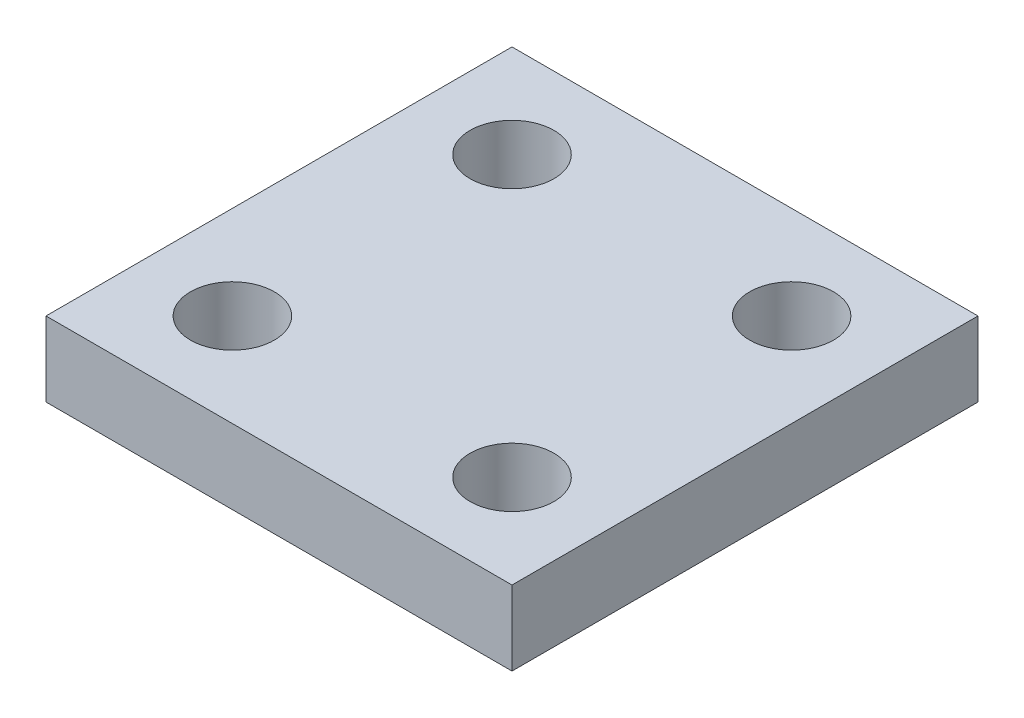
from build123d import *

# Parameters (mm, degrees)
SKETCH_1_W      = 25
SKETCH_1_H      = 25
SKETCH_1_R      = 2.25
EXTRUDE_1_DEPTH = 4


with BuildPart() as part:
    # 草圖1 → 填料-伸長1 (new body)
    with BuildSketch(Plane(origin=(0, 0, 0), x_dir=(1, 0, 0), z_dir=(0, 1, 0))):
        Rectangle(SKETCH_1_W, SKETCH_1_H)
        with Locations((-7.5, 7.5)):
            Circle(SKETCH_1_R, mode=Mode.SUBTRACT)
        with Locations((7.5, -7.5)):
            Circle(SKETCH_1_R, mode=Mode.SUBTRACT)
        with Locations((-7.5, -7.5)):
            Circle(SKETCH_1_R, mode=Mode.SUBTRACT)
        with Locations((7.5, 7.5)):
            Circle(SKETCH_1_R, mode=Mode.SUBTRACT)
    extrude(amount=EXTRUDE_1_DEPTH)


solid = part.part
